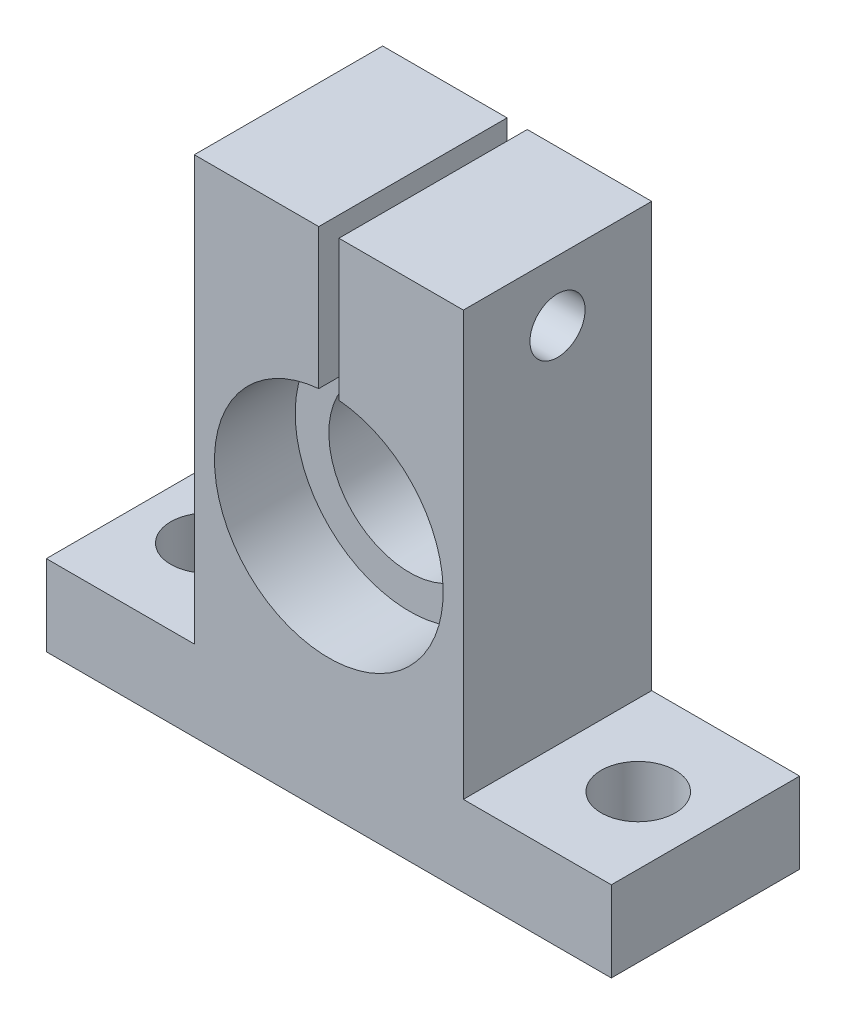
from build123d import *

# Parameters (mm, degrees)
BOSS_EXTRUDE1_DEPTH = 7
SKETCH2_R           = 6
CUT_EXTRUDE1_DEPTH  = 15
SKETCH3_R           = 2.05
CUT_EXTRUDE2_DEPTH  = 32
SKETCH4_R           = 2.75
CUT_EXTRUDE3_DEPTH  = 14
SKETCH5_W           = 1.5
SKETCH5_H           = 29
CUT_EXTRUDE4_DEPTH  = 15
SKETCH6_R           = 8.5
CUT_EXTRUDE5_DEPTH  = 6


with BuildPart() as part:
    # Sketch1 → Boss-Extrude1 (new body, symmetric)
    with BuildSketch(Plane.XY):
        Polygon((0, 0), (21, 0), (21, 6), (10, 6), (10, 37.5), (0, 37.5), align=None)
    boss_extrude1 = extrude(amount=BOSS_EXTRUDE1_DEPTH, both=True)

    # Mirror1: Boss-Extrude1 across plane
    add(boss_extrude1.mirror(Plane(origin=(0, 37.5, 7), x_dir=(0, 0, 1), z_dir=(1, 0, 0))))

    # Sketch2 → Cut-Extrude1 (cut, through all)
    with BuildSketch(Plane.XY.offset(7)):
        with Locations((0, 18.6)):
            Circle(SKETCH2_R)
    extrude(amount=-CUT_EXTRUDE1_DEPTH, mode=Mode.SUBTRACT)

    # Sketch3 → Cut-Extrude2 (cut, through all)
    with BuildSketch(Plane(origin=(10, 0, 0), x_dir=(0, 0, -1), z_dir=(1, 0, 0))):
        with Locations((0, 33)):
            Circle(SKETCH3_R)
    extrude(amount=-CUT_EXTRUDE2_DEPTH, mode=Mode.SUBTRACT)

    # Sketch4 → Cut-Extrude3 (cut)
    with BuildSketch(Plane(origin=(0, 6, 0), x_dir=(1, 0, 0), z_dir=(0, 1, 0))):
        with Locations((-16, 0)):
            Circle(SKETCH4_R)
        with Locations((16, 0)):
            Circle(SKETCH4_R)
    extrude(amount=-CUT_EXTRUDE3_DEPTH, mode=Mode.SUBTRACT)

    # Sketch5 → Cut-Extrude4 (cut, through all)
    with BuildSketch(Plane.XY.offset(7)):
        with Locations((0, 37.5)):
            Rectangle(SKETCH5_W, SKETCH5_H)
    extrude(amount=-CUT_EXTRUDE4_DEPTH, mode=Mode.SUBTRACT)

    # Sketch6 → Cut-Extrude5 (cut)
    with BuildSketch(Plane.XY.offset(7)):
        with Locations((0, 18.6)):
            Circle(SKETCH6_R)
    extrude(amount=-CUT_EXTRUDE5_DEPTH, mode=Mode.SUBTRACT)


solid = part.part
